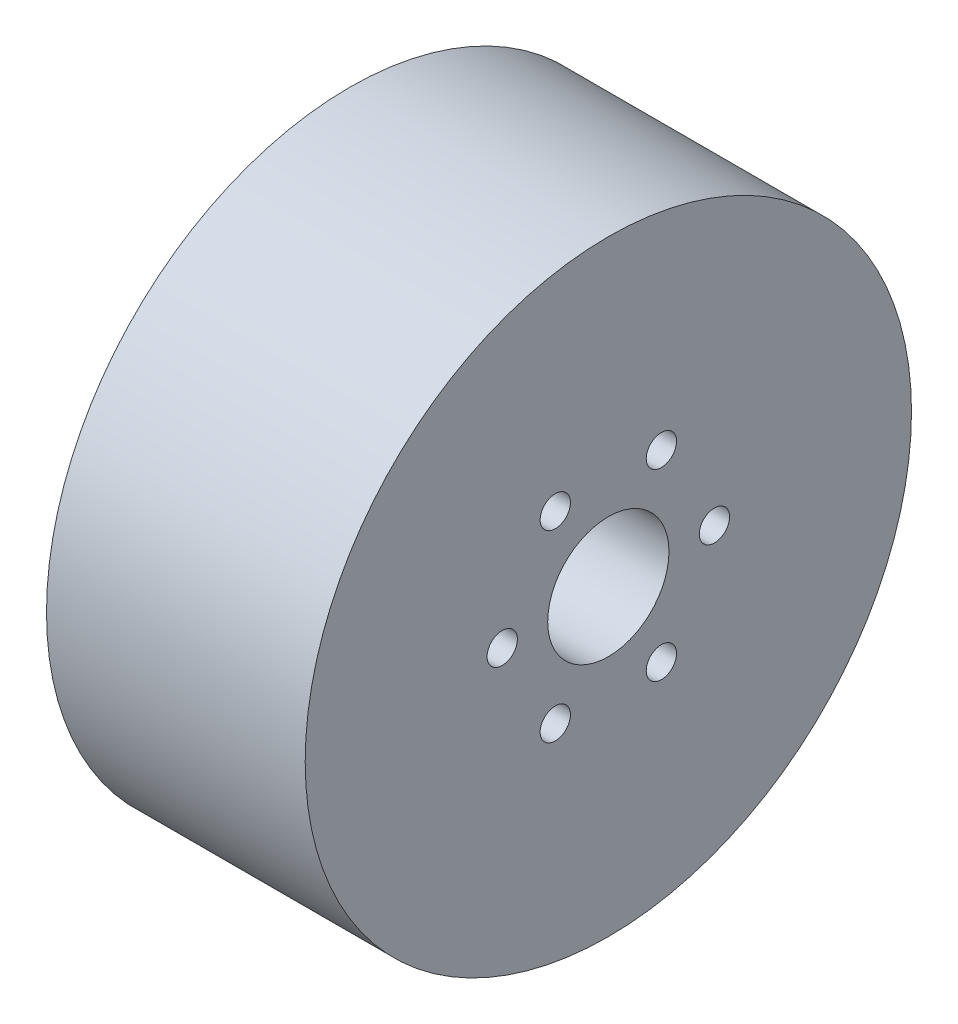
from build123d import *

# Parameters (mm, degrees)
SKETCH_1_R          = 30
EXTRUDE_1_DEPTH     = 25.6
SKETCH_2_R          = 6
SKETCH_2_R_2        = 1.5
CUT_EXTRUDE_1_DEPTH = 30


with BuildPart() as part:
    # ｽｹｯﾁ1 → ﾎﾞｽ - 押し出し1 (new body)
    with BuildSketch(Plane(origin=(0, 0, 0), x_dir=(0, 0, -1), z_dir=(1, 0, 0))):
        Circle(SKETCH_1_R)
    extrude(amount=EXTRUDE_1_DEPTH)

    # ｽｹｯﾁ2 → ｶｯﾄ - 押し出し1 (cut)
    with BuildSketch(Plane.ZY):
        Circle(SKETCH_2_R)
        with Locations((10.5, 0)):
            Circle(SKETCH_2_R_2)
        with Locations((5.25, -9.09326674)):
            Circle(SKETCH_2_R_2)
        with Locations((-5.25, -9.09326674)):
            Circle(SKETCH_2_R_2)
        with Locations((-10.5, 0)):
            Circle(SKETCH_2_R_2)
        with Locations((-5.25, 9.09326674)):
            Circle(SKETCH_2_R_2)
        with Locations((5.25, 9.09326674)):
            Circle(SKETCH_2_R_2)
    extrude(amount=-CUT_EXTRUDE_1_DEPTH, mode=Mode.SUBTRACT)


solid = part.part
